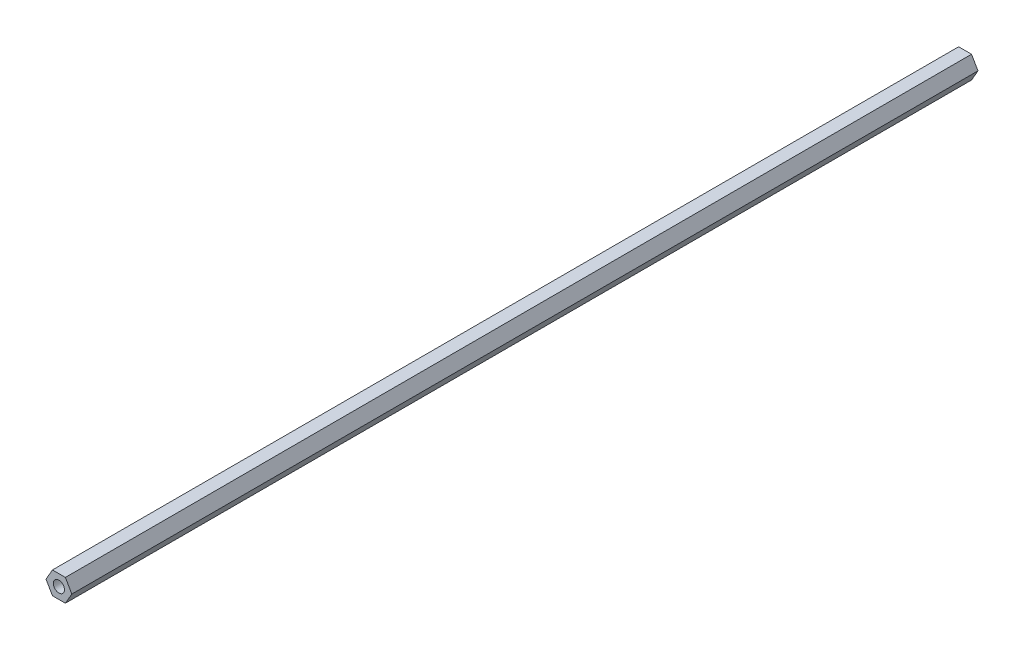
from build123d import *

# Parameters (mm, degrees)
BOSS_EXTRUDE1_DEPTH     = 514.48335
SKETCH2_R               = 3.175
CUT_EXTRUDE1_DEPTH      = 1
CUT_EXTRUDE1_DEPTH_BACK = 515.48335


with BuildPart() as part:
    # Sketch1 → Boss-Extrude1 (new body)
    with BuildSketch(Plane.XY):
        Polygon((-7.332348419, 0), (-3.666174209, -6.35), (3.666174209, -6.35), (7.332348419, 0), (3.666174209, 6.35), (-3.666174209, 6.35), align=None)
    extrude(amount=BOSS_EXTRUDE1_DEPTH)

    # Sketch2 → Cut-Extrude1 (cut, two sides)
    with BuildSketch(Plane.XY.offset(514.48335)) as cut_extrude1_sk:
        Circle(SKETCH2_R)
    extrude(amount=CUT_EXTRUDE1_DEPTH, mode=Mode.SUBTRACT)
    extrude(cut_extrude1_sk.sketch, amount=-CUT_EXTRUDE1_DEPTH_BACK, mode=Mode.SUBTRACT)


solid = part.part
